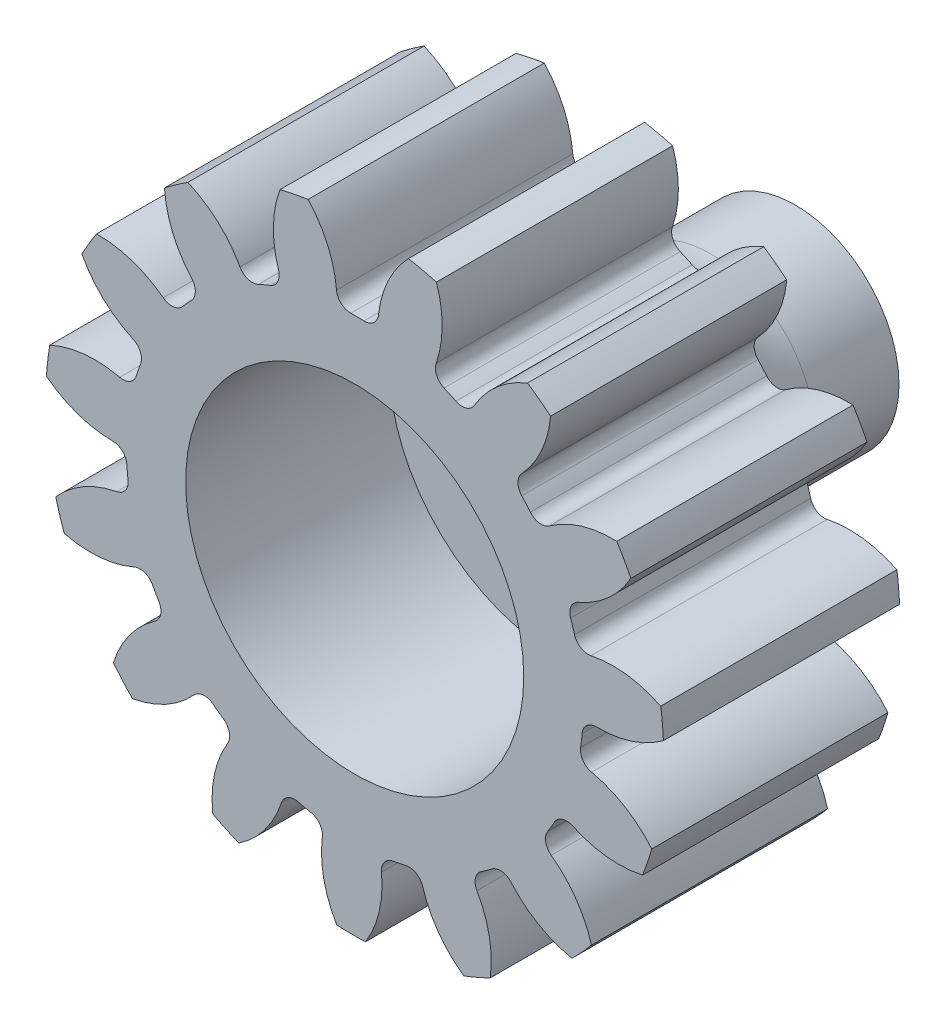
from build123d import *

# Parameters (mm, degrees)
SKETCH3_R          = 21.59
GEARBODY_DEPTH     = 11
TOOTHCUT_DEPTH     = 12
CIRPATTERN1_COUNT  = 15
SCALE1_SCALE_X     = 0.666666667
SCALE1_SCALE_Y     = 0.666666667
SCALE1_SCALE_Z     = 1
BOREDIA_R          = 7.874
BORE_DEPTH         = 12700
SKETCH5_R          = 4.1
CUT_EXTRUDE1_DEPTH = 5.3


with BuildPart() as part:
    # Sketch3 → gearBody (new body)
    with BuildSketch(Plane.XY):
        Circle(SKETCH3_R)
    extrude(amount=GEARBODY_DEPTH)

    # Sketch2 → toothCut (cut, through all)
    with BuildSketch(Plane.XY):
        with BuildLine():
            ThreePointArc((15.783846764, -2.304552616), (15.843293638, -1.852249483), (15.889781974, -1.39843136))
            ThreePointArc((15.889781974, -1.39843136), (16.213055843, -0.751556907), (16.890861518, -0.499501321))
            ThreePointArc((16.890861518, -0.499501321), (20.504912911, 0.340315353), (23.283949955, 2.798691365))
            ThreePointArc((23.283949955, 2.798691365), (23.292901215, -2.723187818), (22.010467945, -8.09409042))
            ThreePointArc((22.010467945, -8.09409042), (19.873444675, -5.060974685), (16.550574786, -3.410158156))
            ThreePointArc((16.550574786, -3.410158156), (15.949189176, -3.008551507), (15.783846764, -2.304552616))
        make_face()
    toothcut = extrude(amount=TOOTHCUT_DEPTH, mode=Mode.SUBTRACT)

    # CirPattern1: toothCut ×15 about axis
    cirpattern1_axis = Axis((0, 0, 0), (0, 0, 1))
    for i in range(1, CIRPATTERN1_COUNT):
        add(toothcut.rotate(cirpattern1_axis, i * 360 / CIRPATTERN1_COUNT), mode=Mode.SUBTRACT)


with BuildPart() as part_1:
    # Scale1: scaled about (0, 0, 5.5)
    add(part.part.scale((SCALE1_SCALE_X, SCALE1_SCALE_Y, SCALE1_SCALE_Z), about=(0, 0, 5.5)))

    # boreDia → bore (cut, symmetric)
    with BuildSketch(Plane.XY):
        Circle(BOREDIA_R)
    extrude(amount=BORE_DEPTH, both=True, mode=Mode.SUBTRACT)

    # Sketch4 → Revolve1 (revolve)
    with BuildSketch(Plane(origin=(0, 0, 0), x_dir=(0, 0, -1), z_dir=(1, 0, 0))):
        with BuildLine():
            Line((9.525, 0), (-1.524, 0))
            Line((-1.524, 0), (-1.524, 7.874))
            Line((-1.524, 7.874), (0, 7.874))
            Line((0, 7.874), (0, 10.414))
            ThreePointArc((0, 10.414), (1.636687307, 6.462687307), (5.588, 4.826))
            Line((5.588, 4.826), (9.525, 4.826))
            Line((9.525, 4.826), (9.525, 0))
        make_face()
    revolve(axis=Axis((0, 0, 0), (0, 0, -1)))

    # Sketch5 → Cut-Extrude1 (cut)
    with BuildSketch(Plane(origin=(0, 0, -9.525), x_dir=(-1, 0, 0), z_dir=(0, 0, -1))):
        Circle(SKETCH5_R)
    extrude(amount=-CUT_EXTRUDE1_DEPTH, mode=Mode.SUBTRACT)


solid = part_1.part
